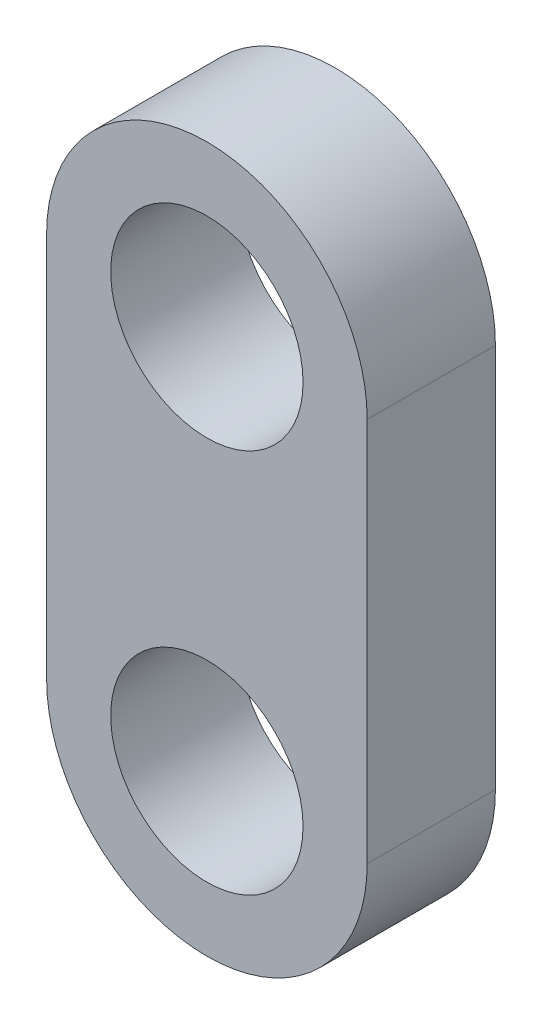
from build123d import *

# Parameters (mm, degrees)
SKETCH1_R           = 7.5
BOSS_EXTRUDE1_DEPTH = 10


with BuildPart() as part:
    # Sketch1 → Boss-Extrude1 (new body)
    with BuildSketch(Plane.XY):
        with BuildLine():
            Line((-12.5, -15), (-12.5, 15))
            ThreePointArc((-12.5, 15), (0, 27.5), (12.5, 15))
            Line((12.5, 15), (12.5, -15))
            ThreePointArc((12.5, -15), (0, -27.5), (-12.5, -15))
        make_face()
        with Locations((0, 15)):
            Circle(SKETCH1_R, mode=Mode.SUBTRACT)
        with Locations((0, -15)):
            Circle(SKETCH1_R, mode=Mode.SUBTRACT)
    extrude(amount=BOSS_EXTRUDE1_DEPTH)


solid = part.part
